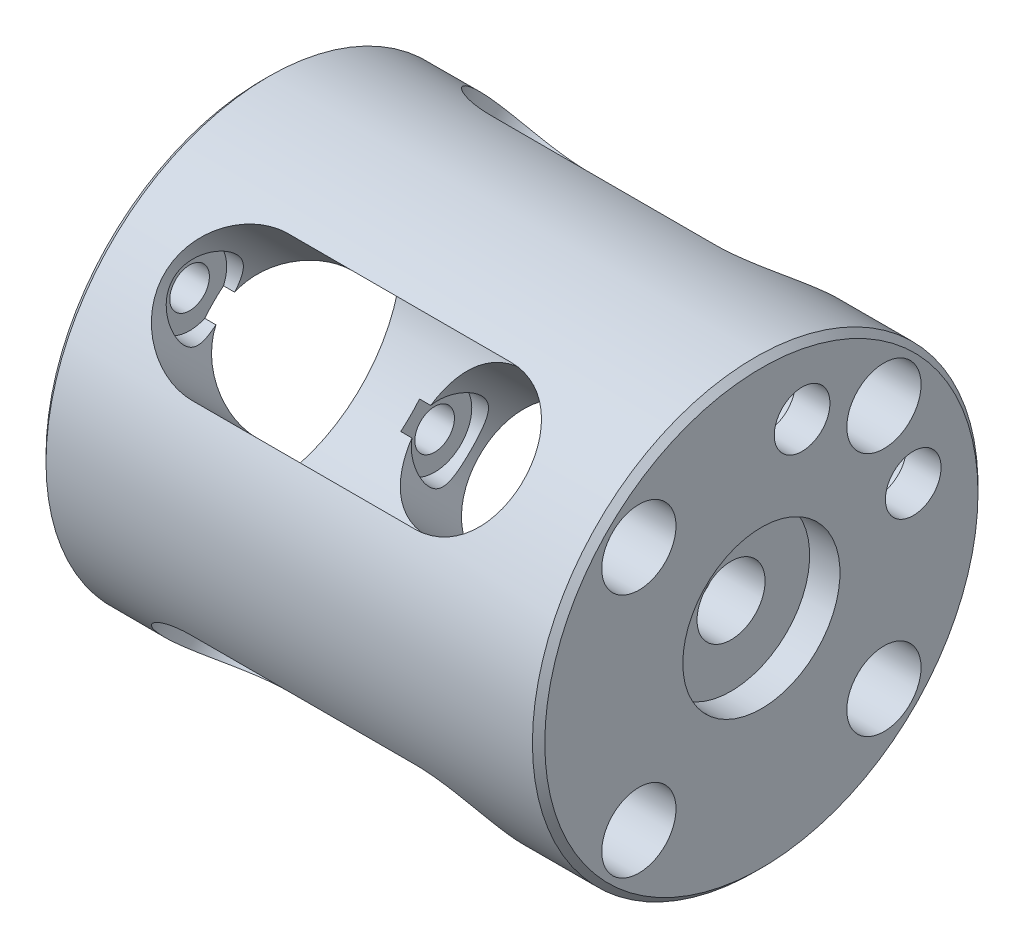
from build123d import *

# Parameters (mm, degrees)
SKETCH7_R               = 1.6
CUT_EXTRUDE1_DEPTH      = 41.3
SKETCH8_R               = 3
CUT_EXTRUDE2_DEPTH      = 36.3
CHAMFER1_SIZE           = 0.5
CUT_EXTRUDE5_DEPTH      = 26.455844123
CUT_EXTRUDE5_DEPTH_BACK = 26.455844123
CUT_EXTRUDE6_DEPTH      = 26.455844264
CUT_EXTRUDE6_DEPTH_BACK = 26.455844264
SKETCH15_R              = 2.25
CUT_EXTRUDE7_DEPTH      = 41.3000001
SKETCH16_R              = 3
CUT_EXTRUDE8_DEPTH      = 37.5


with BuildPart() as part:
    # Sketch2 → Revolve1 (revolve)
    with BuildSketch(Plane(origin=(0, 0, 0), x_dir=(1, 0, 0), z_dir=(0, 1, 0))):
        Polygon((-40.3, 18), (-40.3, 11.25), (-6.3, 11.25), (-6.3, 2.75), (-2.45, 2.75), (-2.45, 6.35), (0, 6.35), (0, 18), align=None)
    revolve(axis=Axis((-68.587301587, 0, 0), (1, 0, 0)))

    # Sketch7 → Cut-Extrude1 (cut, through all)
    with BuildSketch(Plane(origin=(0, 0, 0), x_dir=(0, 0, -1), z_dir=(1, 0, 0))):
        with Locations((-9.899494937, 9.899494937)):
            Circle(SKETCH7_R)
        with Locations((9.899494937, 9.899494937)):
            Circle(SKETCH7_R)
        with Locations((9.899494937, -9.899494937)):
            Circle(SKETCH7_R)
        with Locations((-9.899494937, -9.899494937)):
            Circle(SKETCH7_R)
    extrude(amount=-CUT_EXTRUDE1_DEPTH, mode=Mode.SUBTRACT)

    # Sketch8 → Cut-Extrude2 (cut)
    with BuildSketch(Plane(origin=(0, 0, 0), x_dir=(0, 0, -1), z_dir=(1, 0, 0))):
        with Locations((-9.899494937, 9.899494937)):
            Circle(SKETCH8_R)
        with Locations((9.899494937, 9.899494937)):
            Circle(SKETCH8_R)
        with Locations((-9.899494937, -9.899494937)):
            Circle(SKETCH8_R)
        with Locations((9.899494937, -9.899494937)):
            Circle(SKETCH8_R)
    extrude(amount=-CUT_EXTRUDE2_DEPTH, mode=Mode.SUBTRACT)

    # Chamfer1
    chamfer1_edges = [part.edges().sort_by_distance(p)[0] for p in [
        (0, 0, 18),
        (-40.3, 0, 18),
    ]]
    chamfer(chamfer1_edges, length=CHAMFER1_SIZE)

    # Sketch13 → Cut-Extrude5 (cut, two sides)
    with BuildSketch(Plane(origin=(0, 0, 0), x_dir=(-1, 0, 0), z_dir=(0, 0.707106781, -0.707106781))) as cut_extrude5_sk:
        with BuildLine():
            Line((12, 5.5), (30, 5.5))
            ThreePointArc((30, 5.5), (35.5, 0), (30, -5.5))
            Line((30, -5.5), (12, -5.5))
            ThreePointArc((12, -5.5), (6.5, 0), (12, 5.5))
        make_face()
    extrude(amount=CUT_EXTRUDE5_DEPTH, mode=Mode.SUBTRACT)
    extrude(cut_extrude5_sk.sketch, amount=-CUT_EXTRUDE5_DEPTH_BACK, mode=Mode.SUBTRACT)

    # Sketch14 → Cut-Extrude6 (cut, two sides)
    with BuildSketch(Plane(origin=(0, 0, 0), x_dir=(-1, 0, 0), z_dir=(0, -0.707106781, -0.707106781))) as cut_extrude6_sk:
        with BuildLine():
            Line((12, 5.5), (30, 5.5))
            ThreePointArc((30, 5.5), (35.5, 0), (30, -5.5))
            Line((30, -5.5), (12, -5.5))
            ThreePointArc((12, -5.5), (6.5, 0), (12, 5.5))
        make_face()
    extrude(amount=CUT_EXTRUDE6_DEPTH, mode=Mode.SUBTRACT)
    extrude(cut_extrude6_sk.sketch, amount=-CUT_EXTRUDE6_DEPTH_BACK, mode=Mode.SUBTRACT)

    # Sketch15 → Cut-Extrude7 (cut, through all)
    with BuildSketch(Plane(origin=(0, 0, 0), x_dir=(0, 0, -1), z_dir=(1, 0, 0))):
        with Locations((3.287001873, 12.267257994)):
            Circle(SKETCH15_R)
        with Locations((12.267257994, 3.287001873)):
            Circle(SKETCH15_R)
    extrude(amount=-CUT_EXTRUDE7_DEPTH, mode=Mode.SUBTRACT)

    # Sketch16 → Cut-Extrude8 (cut)
    with BuildSketch(Plane.ZY.offset(40.3)):
        with Locations((-12.267257994, 3.287001873)):
            Circle(SKETCH16_R)
        with Locations((-3.287001873, 12.267257994)):
            Circle(SKETCH16_R)
    extrude(amount=-CUT_EXTRUDE8_DEPTH, mode=Mode.SUBTRACT)


solid = part.part
